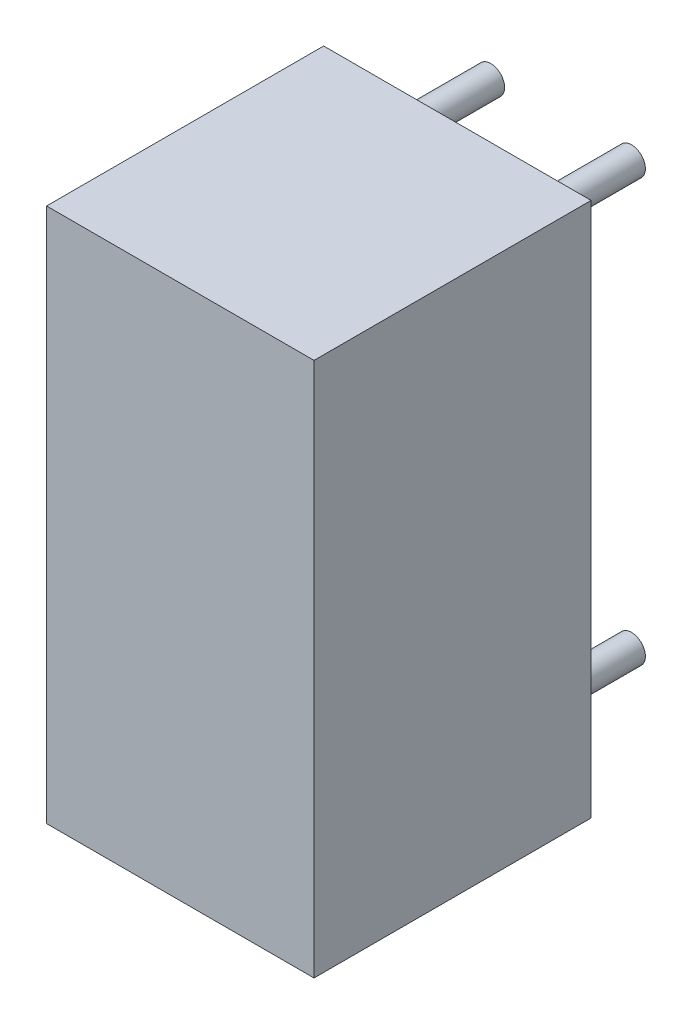
from build123d import *

# Parameters (mm, degrees)
SKETCH1_W               = 4.826
SKETCH1_H               = 9.652
COMPONENT_OUTLINE_DEPTH = 5
SKETCH2_R               = 0.25
EXTRUDE_1_DEPTH         = 2
SKETCH3_R               = 0.25
EXTRUDE_2_DEPTH         = 2
SKETCH4_R               = 0.25
EXTRUDE_3_DEPTH         = 2
SKETCH5_R               = 0.25
EXTRUDE_4_DEPTH         = 2


with BuildPart() as part:
    # Sketch1 → Component_Outline (new body)
    with BuildSketch(Plane.XY):
        with Locations((1.397, 3.81)):
            Rectangle(SKETCH1_W, SKETCH1_H)
    extrude(amount=COMPONENT_OUTLINE_DEPTH)


with BuildPart() as body_2:
    # Sketch2 → Extrude 1 (new body)
    with BuildSketch(Plane.XY):
        Circle(SKETCH2_R)
    extrude(amount=-EXTRUDE_1_DEPTH)


with BuildPart() as body_3:
    # Sketch3 → Extrude 2 (new body)
    with BuildSketch(Plane.XY):
        with Locations((2.54, 0)):
            Circle(SKETCH3_R)
    extrude(amount=-EXTRUDE_2_DEPTH)


with BuildPart() as body_4:
    # Sketch4 → Extrude 3 (new body)
    with BuildSketch(Plane.XY):
        with Locations((2.54, 7.62)):
            Circle(SKETCH4_R)
    extrude(amount=-EXTRUDE_3_DEPTH)


with BuildPart() as body_5:
    # Sketch5 → Extrude 4 (new body)
    with BuildSketch(Plane.XY):
        with Locations((0, 7.62)):
            Circle(SKETCH5_R)
    extrude(amount=-EXTRUDE_4_DEPTH)


solid = Compound([part.part, body_2.part, body_3.part, body_4.part, body_5.part])
